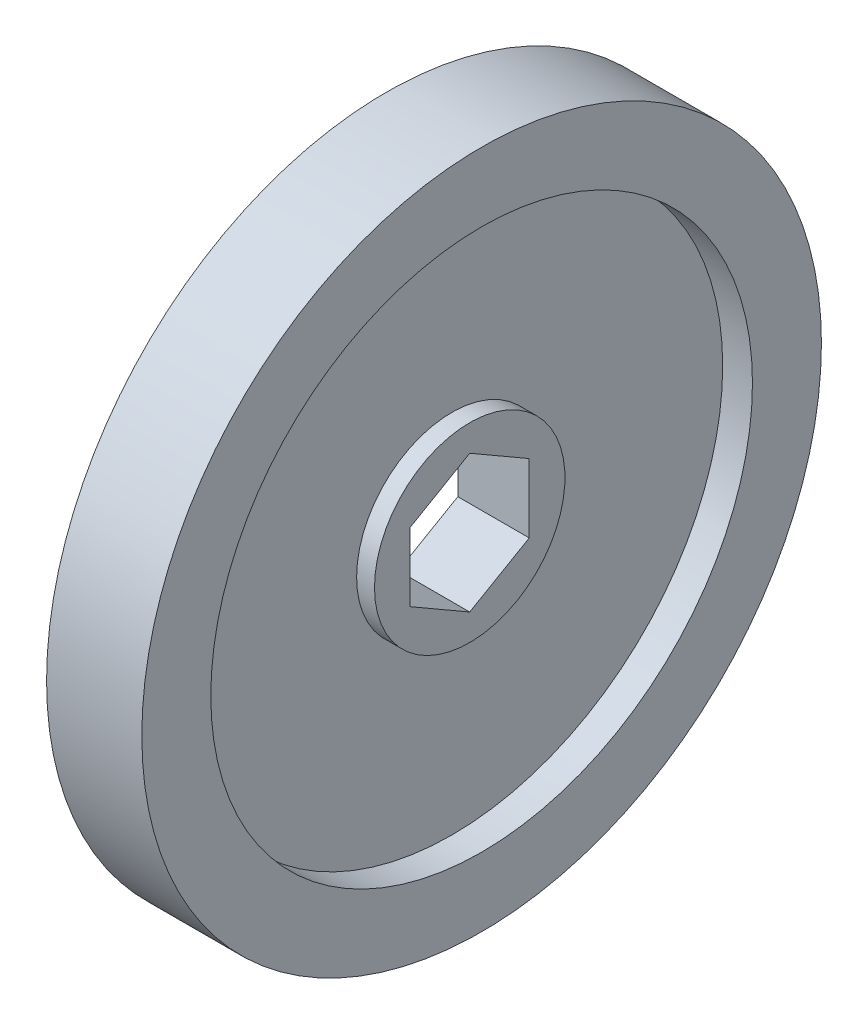
from build123d import *

# Parameters (mm, degrees)
ENL_V_MAT_EXTRU_1_DEPTH = 9.89


with BuildPart() as part:
    # Esquisse1 → Révolution1 (revolve)
    with BuildSketch(Plane.XY):
        Polygon((-5.08, 36.25), (5.08, 36.25), (5.08, 28.8925), (1.905, 28.8925), (1.905, 10.16), (3.81, 10.16), (3.81, 0), (-3.81, 0), (-3.81, 10.16), (-1.905, 10.16), (-1.905, 28.8925), (-5.08, 28.8925), align=None)
    revolve(axis=Axis((-12.56603466, 0, 0), (1, 0, 0)))

    # Esquisse2 → Enlèv. mat.-Extru.1 (cut, through all)
    with BuildSketch(Plane(origin=(3.81, 0, 0), x_dir=(0, 0, -1), z_dir=(1, 0, 0))):
        Polygon((0, 7.332348419), (-6.35, 3.666174209), (-6.35, -3.666174209), (0, -7.332348419), (6.35, -3.666174209), (6.35, 3.666174209), align=None)
    extrude(amount=-ENL_V_MAT_EXTRU_1_DEPTH, mode=Mode.SUBTRACT)


solid = part.part
